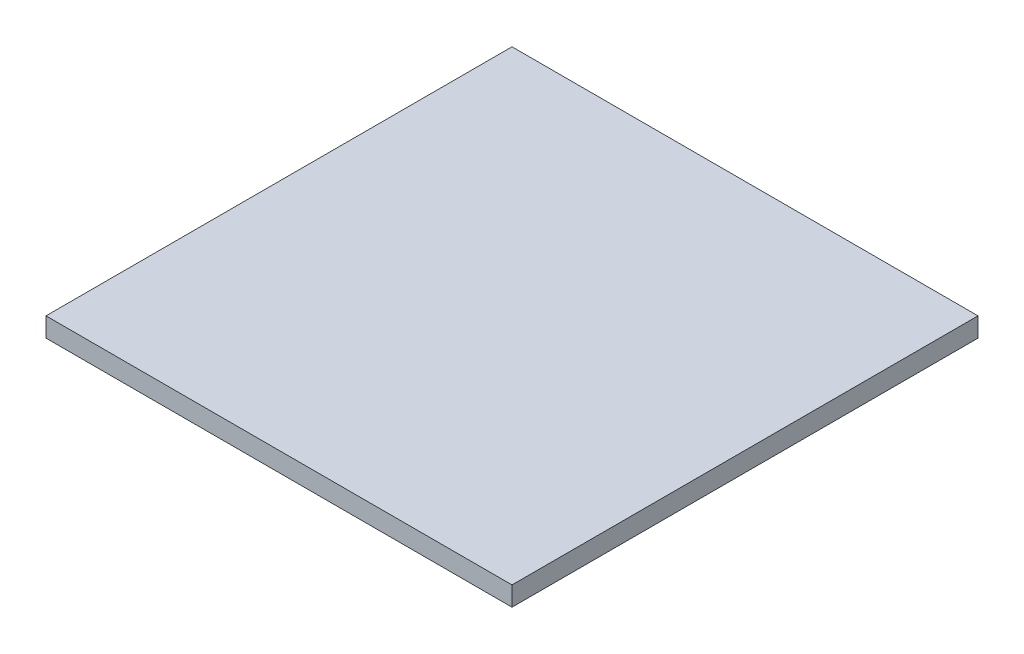
from build123d import *

# Parameters (mm, degrees)
SKETCH1_W           = 1219.2
SKETCH1_H           = 50.565898618
BOSS_EXTRUDE1_DEPTH = 1219.2


with BuildPart() as part:
    # Sketch1 → Boss-Extrude1 (new body)
    with BuildSketch(Plane.XY):
        with Locations((609.6, 25.282949309)):
            Rectangle(SKETCH1_W, SKETCH1_H)
    extrude(amount=BOSS_EXTRUDE1_DEPTH)


solid = part.part
